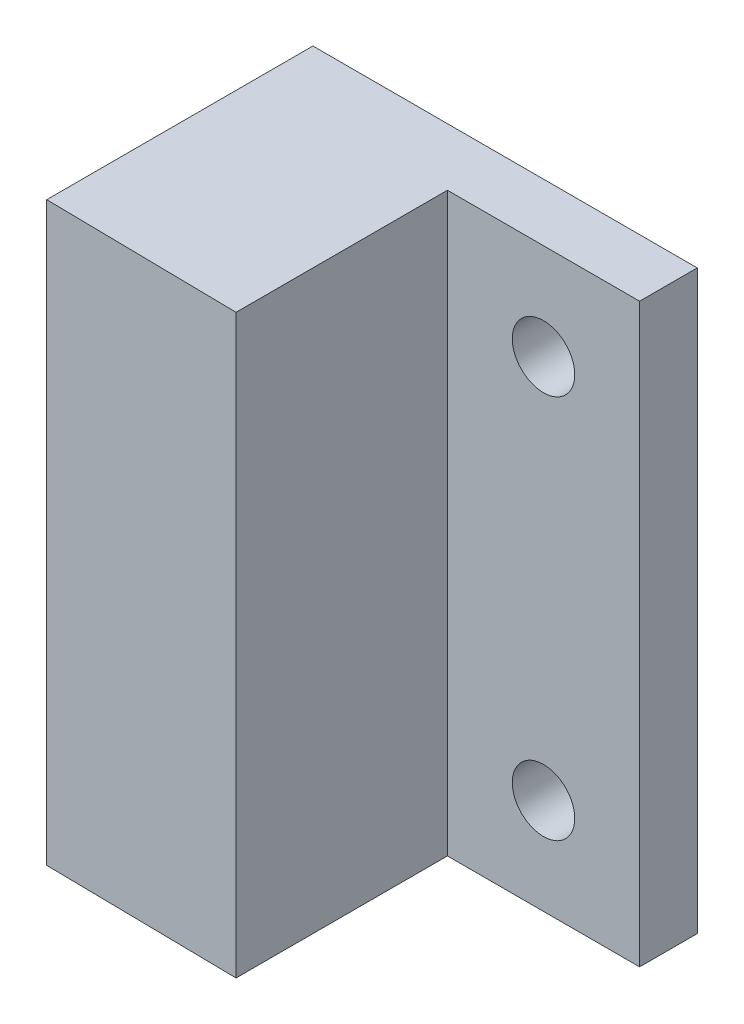
from build123d import *

# Parameters (mm, degrees)
ESQUISSE1_W             = 10
ESQUISSE1_H             = 30
BOSS_EXTRU_1_DEPTH      = 14
ESQUISSE2_W             = 3
ESQUISSE2_H             = 30
BOSS_EXTRU_2_DEPTH      = 10
ESQUISSE3_R             = 1.625
ENL_V_MAT_EXTRU_1_DEPTH = 4
ENL_V_MAT_EXTRU_2_DEPTH = 31


with BuildPart() as part:
    # Esquisse1 → Boss.-Extru.1 (new body)
    with BuildSketch(Plane.XY):
        with Locations((5, -15)):
            Rectangle(ESQUISSE1_W, ESQUISSE1_H)
    extrude(amount=BOSS_EXTRU_1_DEPTH)

    # Esquisse2 → Boss.-Extru.2 (add)
    with BuildSketch(Plane(origin=(10, 0, 0), x_dir=(0, 0, -1), z_dir=(1, 0, 0))):
        with Locations((-1.5, -15)):
            Rectangle(ESQUISSE2_W, ESQUISSE2_H)
    extrude(amount=BOSS_EXTRU_2_DEPTH)

    # Esquisse3 → Enlèv. mat.-Extru.1 (cut, through all)
    with BuildSketch(Plane.XY.offset(3)):
        with Locations((15, -5)):
            Circle(ESQUISSE3_R)
        with Locations((15, -25)):
            Circle(ESQUISSE3_R)
    extrude(amount=-ENL_V_MAT_EXTRU_1_DEPTH, mode=Mode.SUBTRACT)

    # Esquisse4 → Enlèv. mat.-Extru.2 (cut, through all)
    with BuildSketch(Plane.XZ.offset(30)):
        Polygon((10, 14), (0, 14), (0, 13.85), align=None)
    extrude(amount=-ENL_V_MAT_EXTRU_2_DEPTH, mode=Mode.SUBTRACT)


solid = part.part
